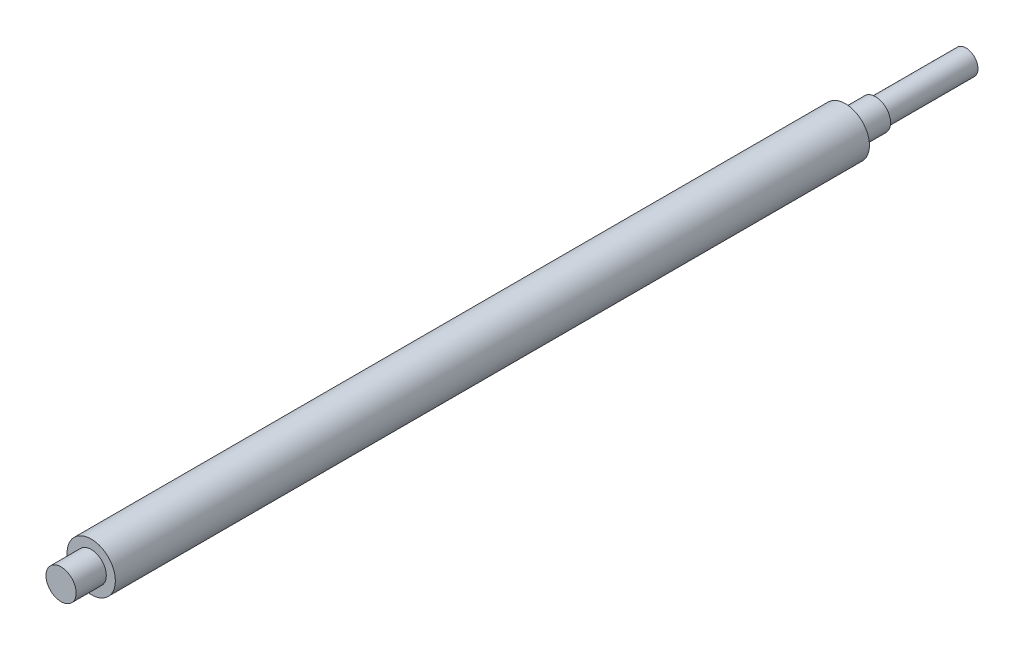
from build123d import *

# Parameters (mm, degrees)
SKETCH1_R           = 8
BOSS_EXTRUDE1_DEPTH = 250
SKETCH2_R           = 5
BOSS_EXTRUDE2_DEPTH = 10
SKETCH3_R           = 5
BOSS_EXTRUDE3_DEPTH = 10
SKETCH4_R           = 4
BOSS_EXTRUDE4_DEPTH = 30


with BuildPart() as part:
    # Sketch1 → Boss-Extrude1 (new body)
    with BuildSketch(Plane.XY):
        Circle(SKETCH1_R)
    extrude(amount=BOSS_EXTRUDE1_DEPTH)

    # Sketch2 → Boss-Extrude2 (add)
    with BuildSketch(Plane.XY.offset(250)):
        Circle(SKETCH2_R)
    extrude(amount=BOSS_EXTRUDE2_DEPTH)

    # Sketch3 → Boss-Extrude3 (add)
    with BuildSketch(Plane(origin=(0, 0, 0), x_dir=(-1, 0, 0), z_dir=(0, 0, -1))):
        Circle(SKETCH3_R)
    extrude(amount=BOSS_EXTRUDE3_DEPTH)

    # Sketch4 → Boss-Extrude4 (add)
    with BuildSketch(Plane(origin=(0, 0, -10), x_dir=(-1, 0, 0), z_dir=(0, 0, -1))):
        Circle(SKETCH4_R)
    extrude(amount=BOSS_EXTRUDE4_DEPTH)


solid = part.part
